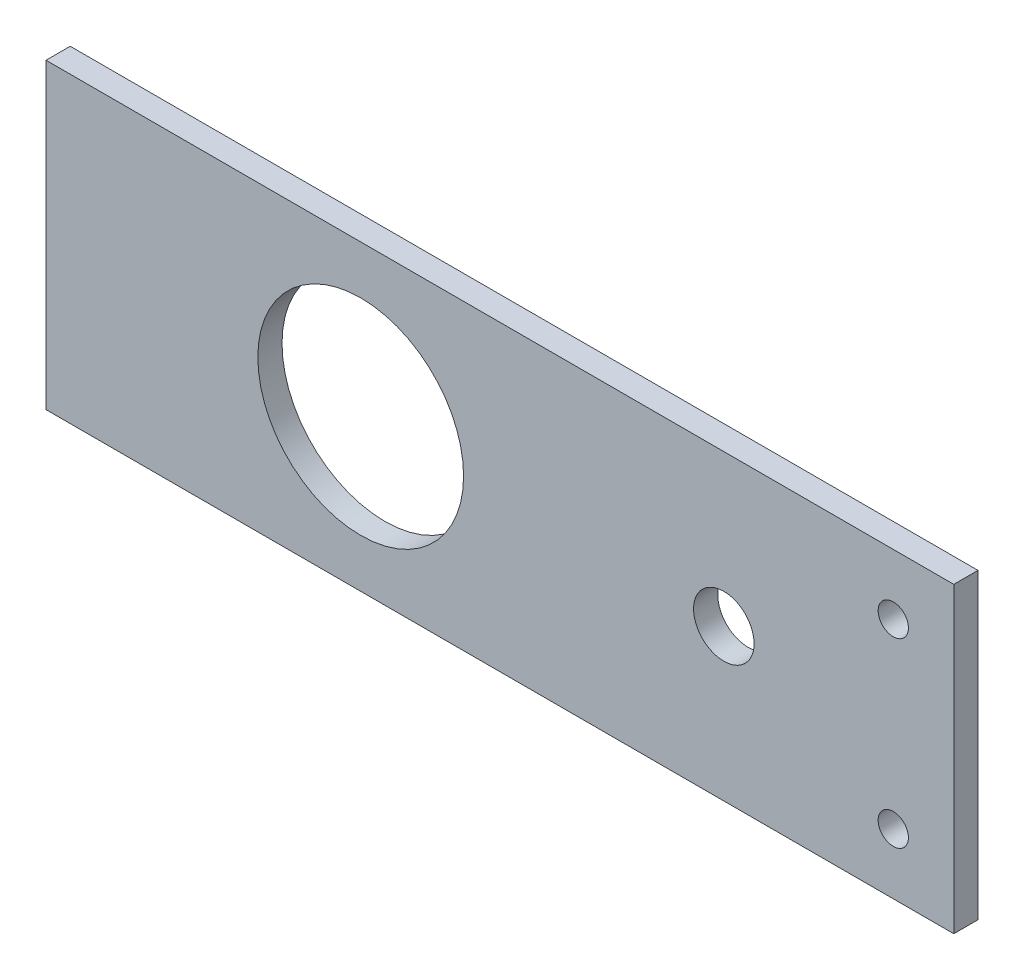
from build123d import *

# Parameters (mm, degrees)
SKETCH1_W           = 150
SKETCH1_H           = 50
SKETCH1_R           = 5
SKETCH1_R_2         = 17
BOSS_EXTRUDE2_DEPTH = 4
SKETCH3_R           = 2.5
CUT_EXTRUDE1_DEPTH  = 10


with BuildPart() as part:
    # Sketch1 → Boss-Extrude2 (new body)
    with BuildSketch(Plane.XY):
        Rectangle(SKETCH1_W, SKETCH1_H)
        with Locations((37, 0)):
            Circle(SKETCH1_R, mode=Mode.SUBTRACT)
        with Locations((-23, 0)):
            Circle(SKETCH1_R_2, mode=Mode.SUBTRACT)
    extrude(amount=BOSS_EXTRUDE2_DEPTH)

    # Sketch3 → Cut-Extrude1 (cut)
    with BuildSketch(Plane.XY.offset(4)):
        with Locations((65, 15)):
            Circle(SKETCH3_R)
        with Locations((65, -15)):
            Circle(SKETCH3_R)
    extrude(amount=-CUT_EXTRUDE1_DEPTH, mode=Mode.SUBTRACT)


solid = part.part
